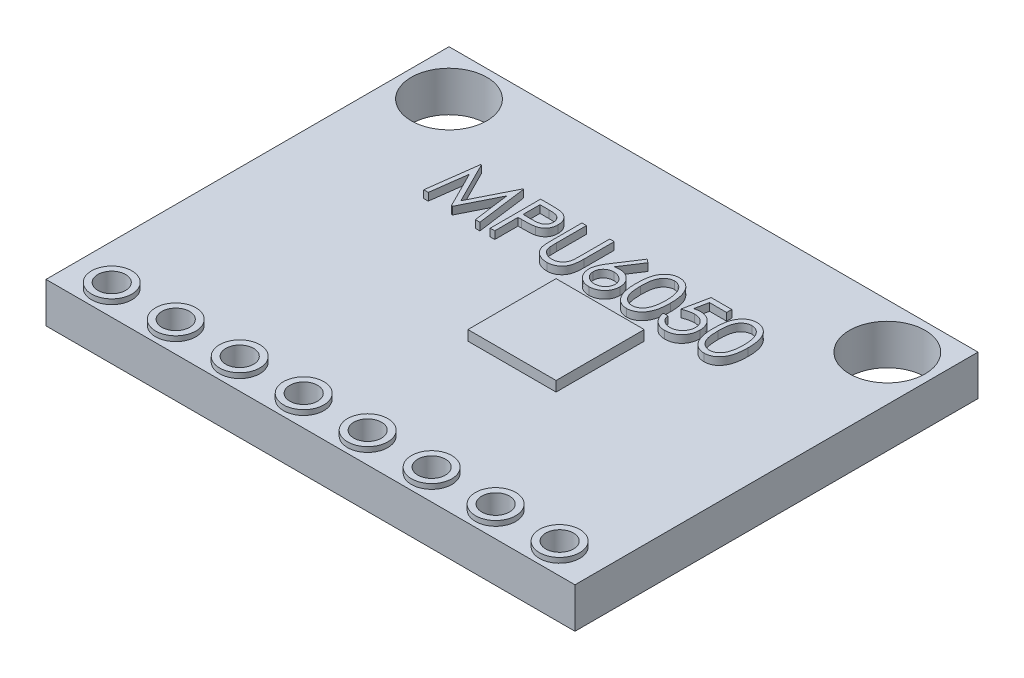
from build123d import *

# Parameters (mm, degrees)
SKETCH1_W           = 21
SKETCH1_H           = 16
SKETCH1_W_2         = 3.5
SKETCH1_H_2         = 3.5
SKETCH1_R           = 0.8
SKETCH1_R_2         = 1.5
BOSS_EXTRUDE1_DEPTH = 1.6
SKETCH1_3_W         = 3.5
SKETCH1_3_H         = 3.5
BOSS_EXTRUDE2_DEPTH = 2
SKETCH1_4_R         = 0.8
SKETCH1_4_R_2       = 0.55
BOSS_EXTRUDE3_DEPTH = 1.8
BOSS_EXTRUDE4_DEPTH = 0.3


with BuildPart() as part:
    # Sketch1 → Boss-Extrude1 (new body)
    with BuildSketch(Plane(origin=(0, 0, 0), x_dir=(1, 0, 0), z_dir=(0, 1, 0))):
        with Locations((10.5, 8)):
            Rectangle(SKETCH1_W, SKETCH1_H)
        with Locations((12.25, 8)):
            Rectangle(SKETCH1_W_2, SKETCH1_H_2, mode=Mode.SUBTRACT)
        with Locations((11.77, 1)):
            Circle(SKETCH1_R, mode=Mode.SUBTRACT)
        with Locations((14.31, 1)):
            Circle(SKETCH1_R, mode=Mode.SUBTRACT)
        with Locations((16.85, 1)):
            Circle(SKETCH1_R, mode=Mode.SUBTRACT)
        with Locations((19.39, 1)):
            Circle(SKETCH1_R, mode=Mode.SUBTRACT)
        with Locations((19.2, 14.2)):
            Circle(SKETCH1_R_2, mode=Mode.SUBTRACT)
        with Locations((9.23, 1)):
            Circle(SKETCH1_R, mode=Mode.SUBTRACT)
        with Locations((1.8, 14.2)):
            Circle(SKETCH1_R_2, mode=Mode.SUBTRACT)
        with Locations((1.61, 1)):
            Circle(SKETCH1_R, mode=Mode.SUBTRACT)
        with Locations((4.15, 1)):
            Circle(SKETCH1_R, mode=Mode.SUBTRACT)
        with Locations((6.69, 1)):
            Circle(SKETCH1_R, mode=Mode.SUBTRACT)
    extrude(amount=BOSS_EXTRUDE1_DEPTH)

    # Sketch1_3 → Boss-Extrude2 (add)
    with BuildSketch(Plane(origin=(0, 0, 0), x_dir=(1, 0, 0), z_dir=(0, 1, 0))):
        with Locations((12.25, 8)):
            Rectangle(SKETCH1_3_W, SKETCH1_3_H)
    extrude(amount=BOSS_EXTRUDE2_DEPTH)

    # Sketch1_4 → Boss-Extrude3 (add)
    # profile 1 of 8: a face of its own
    with BuildSketch(Plane(origin=(0, 0, 0), x_dir=(1, 0, 0), z_dir=(0, 1, 0))):
        with Locations((1.61, 1)):
            Circle(SKETCH1_4_R)
        with Locations((1.61, 1)):
            Circle(SKETCH1_4_R_2, mode=Mode.SUBTRACT)
    # profile 2 of 8: a face of its own
    with BuildSketch(Plane(origin=(0, 0, 0), x_dir=(1, 0, 0), z_dir=(0, 1, 0))):
        with Locations((4.15, 1)):
            Circle(SKETCH1_4_R)
        with Locations((4.15, 1)):
            Circle(SKETCH1_4_R_2, mode=Mode.SUBTRACT)
    # profile 3 of 8: a face of its own
    with BuildSketch(Plane(origin=(0, 0, 0), x_dir=(1, 0, 0), z_dir=(0, 1, 0))):
        with Locations((6.69, 1)):
            Circle(SKETCH1_4_R)
        with Locations((6.69, 1)):
            Circle(SKETCH1_4_R_2, mode=Mode.SUBTRACT)
    # profile 4 of 8: a face of its own
    with BuildSketch(Plane(origin=(0, 0, 0), x_dir=(1, 0, 0), z_dir=(0, 1, 0))):
        with Locations((9.23, 1)):
            Circle(SKETCH1_4_R)
        with Locations((9.23, 1)):
            Circle(SKETCH1_4_R_2, mode=Mode.SUBTRACT)
    # profile 5 of 8: a face of its own
    with BuildSketch(Plane(origin=(0, 0, 0), x_dir=(1, 0, 0), z_dir=(0, 1, 0))):
        with Locations((11.77, 1)):
            Circle(SKETCH1_4_R)
        with Locations((11.77, 1)):
            Circle(SKETCH1_4_R_2, mode=Mode.SUBTRACT)
    # profile 6 of 8: a face of its own
    with BuildSketch(Plane(origin=(0, 0, 0), x_dir=(1, 0, 0), z_dir=(0, 1, 0))):
        with Locations((14.31, 1)):
            Circle(SKETCH1_4_R)
        with Locations((14.31, 1)):
            Circle(SKETCH1_4_R_2, mode=Mode.SUBTRACT)
    # profile 7 of 8: a face of its own
    with BuildSketch(Plane(origin=(0, 0, 0), x_dir=(1, 0, 0), z_dir=(0, 1, 0))):
        with Locations((16.85, 1)):
            Circle(SKETCH1_4_R)
        with Locations((16.85, 1)):
            Circle(SKETCH1_4_R_2, mode=Mode.SUBTRACT)
    # profile 8 of 8: a face of its own
    with BuildSketch(Plane(origin=(0, 0, 0), x_dir=(1, 0, 0), z_dir=(0, 1, 0))):
        with Locations((19.39, 1)):
            Circle(SKETCH1_4_R)
        with Locations((19.39, 1)):
            Circle(SKETCH1_4_R_2, mode=Mode.SUBTRACT)
    extrude(amount=BOSS_EXTRUDE3_DEPTH)

    # Sketch3 → Boss-Extrude4 (add)
    # profile 1 of 7: a face of its own
    with BuildSketch(Plane(origin=(0, 1.6, 0), x_dir=(1, 0, 0), z_dir=(0, 1, 0))):
        Polygon((4.716844776, 10.278041451), (4.980867212, 12.278041451), (5.006508237, 12.278041451), (5.832229391, 10.63701581), (6.65594734, 12.278041451), (6.681989007, 12.278041451), (6.947614007, 10.278041451), (6.767325545, 10.278041451), (6.575819135, 11.717144015), (5.853864007, 10.278041451), (5.813399263, 10.278041451), (5.088639648, 11.720349143), (4.897533878, 10.278041451), align=None)
    # profile 2 of 7: a face of its own
    with BuildSketch(Plane(origin=(0, 1.6, 0), x_dir=(1, 0, 0), z_dir=(0, 1, 0))):
        with BuildLine():
            Line((7.357870417, 12.278041451), (7.750097981, 12.278041451))
            add(Edge.make_bspline(
                [(7.750097981, 12.278041451), (7.777075642, 12.278011796), (7.828766038, 12.277954975), (7.902888927, 12.276232264), (7.970208773, 12.273931297), (8.030580419, 12.270741643), (8.084189618, 12.266972163), (8.13079379, 12.261685284), (8.17075925, 12.256165115), (8.194705793, 12.250552882), (8.205626827, 12.247993374)],
                knots=[0, 0, 0, 0, 1.415646017, 2.712440637, 3.8905458, 4.950247383, 5.884950622, 6.709939814, 7.411656543, 8, 8, 8, 8], degree=3))
            add(Edge.make_bspline(
                [(8.205626827, 12.247993374), (8.219451704, 12.244209402), (8.246775691, 12.236730624), (8.286147715, 12.221751354), (8.323607056, 12.203990117), (8.359282232, 12.183747865), (8.392734851, 12.160156114), (8.424464017, 12.13417119), (8.45418972, 12.105193151), (8.481744801, 12.073547014), (8.5070504, 12.039764036), (8.52883879, 12.003339905), (8.54708292, 11.964887732), (8.562730503, 11.924434262), (8.573992477, 11.881639792), (8.58247642, 11.836801671), (8.58786135, 11.789924705), (8.5883771, 11.757890495), (8.588639648, 11.741583117)],
                knots=[0, 0, 0, 0, 0.999701418, 1.975846123, 2.934577507, 3.890451536, 4.834027766, 5.787354733, 6.749476667, 7.726910423, 8.712836071, 9.690891519, 10.682875813, 11.679750201, 12.712814741, 13.765529915, 14.8625177, 16, 16, 16, 16], degree=3))
            add(Edge.make_bspline(
                [(8.588639648, 11.741583117), (8.588398834, 11.725138673), (8.587927664, 11.692964008), (8.582272644, 11.645893844), (8.574655392, 11.600911906), (8.562942791, 11.558117935), (8.547602406, 11.517766066), (8.529606947, 11.479239648), (8.507902073, 11.443194121), (8.48296217, 11.409498625), (8.455218402, 11.378121532), (8.424788151, 11.349290221), (8.39179427, 11.323173456), (8.356341614, 11.299712689), (8.318084557, 11.279451957), (8.277603327, 11.261304926), (8.23454606, 11.24606432), (8.204750338, 11.238047142), (8.189601186, 11.233970938)],
                knots=[0, 0, 0, 0, 1.121902311, 2.195077645, 3.232258892, 4.234102512, 5.217864754, 6.176164875, 7.132989551, 8.084763148, 9.034132444, 9.988522005, 10.94243251, 11.903244335, 12.886203696, 13.894208494, 14.929344452, 16, 16, 16, 16], degree=3))
            add(Edge.make_bspline(
                [(8.189601186, 11.233970938), (8.177071281, 11.231306377), (8.149611265, 11.225466838), (8.104386853, 11.21894772), (8.051732346, 11.213383376), (7.991719615, 11.209211298), (7.924402527, 11.205639659), (7.849744665, 11.202800748), (7.767599478, 11.201240831), (7.710301625, 11.201160378), (7.680386443, 11.201118374)],
                knots=[0, 0, 0, 0, 0.601384939, 1.31797006, 2.144135048, 3.087295005, 4.142315834, 5.309527816, 6.595305764, 8, 8, 8, 8], degree=3))
            Line((7.680386443, 11.201118374), (7.537357596, 11.201118374))
            Line((7.537357596, 11.201118374), (7.537357596, 10.278041451))
            Line((7.537357596, 10.278041451), (7.357870417, 10.278041451))
            Line((7.357870417, 10.278041451), (7.357870417, 12.278041451))
        make_face()
        with BuildLine():
            Line((7.537357596, 12.072913246), (7.537357596, 11.406246579))
            Line((7.537357596, 11.406246579), (7.887517853, 11.401839528))
            add(Edge.make_bspline(
                [(7.887517853, 11.401839528), (7.904614953, 11.401830691), (7.937620553, 11.401813633), (7.985298395, 11.404090903), (8.029532274, 11.406719779), (8.070186317, 11.410568878), (8.107278851, 11.416009597), (8.140871724, 11.421502019), (8.170704457, 11.42944794), (8.205618287, 11.440146837), (8.244523057, 11.458394046), (8.28684737, 11.484879697), (8.322716277, 11.518640102), (8.353755304, 11.556598863), (8.378387234, 11.598826937), (8.396419229, 11.644009186), (8.407014176, 11.691682243), (8.408434859, 11.724304037), (8.409152468, 11.740781835)],
                knots=[0, 0, 0, 0, 1.160613943, 2.240541288, 3.23993089, 4.169200891, 5.011653406, 5.7853311, 6.478053781, 7.106038997, 8.262395093, 9.384106736, 10.481365981, 11.59014053, 12.70357646, 13.786202915, 14.881775077, 16, 16, 16, 16], degree=3))
            add(Edge.make_bspline(
                [(8.409152468, 11.740781835), (8.408430956, 11.756860986), (8.406996679, 11.788824347), (8.396336186, 11.835669353), (8.378422292, 11.88037547), (8.353589952, 11.922074376), (8.323452164, 11.95989655), (8.288423968, 11.992752051), (8.248587818, 12.019164452), (8.211531686, 12.036212042), (8.178616723, 12.046620771), (8.150027031, 12.053903537), (8.117746646, 12.059718169), (8.081765058, 12.064426456), (8.042361153, 12.068457005), (7.999196401, 12.071191849), (7.952434319, 12.072792682), (7.919971136, 12.072872085), (7.903142853, 12.072913246)],
                knots=[0, 0, 0, 0, 1.120700087, 2.227813068, 3.331159281, 4.466773991, 5.599788987, 6.693661531, 7.80175334, 8.91857717, 9.525282508, 10.207424825, 10.974604443, 11.810962634, 12.737642355, 13.736264703, 14.826523623, 16, 16, 16, 16], degree=3))
            Line((7.903142853, 12.072913246), (7.537357596, 12.072913246))
        make_face(mode=Mode.SUBTRACT)
    # profile 3 of 7: a face of its own
    with BuildSketch(Plane(origin=(0, 1.6, 0), x_dir=(1, 0, 0), z_dir=(0, 1, 0))):
        with BuildLine():
            Line((8.998896058, 12.278041451), (9.178383237, 12.278041451))
            Line((9.178383237, 12.278041451), (9.178383237, 11.079724143))
            add(Edge.make_bspline(
                [(9.178383237, 11.079724143), (9.178356527, 11.062763723), (9.178305838, 11.030578402), (9.178644418, 10.984767945), (9.179592628, 10.944040825), (9.180190434, 10.908240055), (9.181520338, 10.877529914), (9.182604937, 10.851744022), (9.18399954, 10.831004478), (9.185675608, 10.818901091), (9.186396058, 10.813698502)],
                knots=[0, 0, 0, 0, 1.528628734, 2.90083645, 4.128790002, 5.200304208, 6.127813768, 6.898992206, 7.526736466, 8, 8, 8, 8], degree=3))
            add(Edge.make_bspline(
                [(9.186396058, 10.813698502), (9.189354606, 10.794928923), (9.195104998, 10.758447363), (9.209760071, 10.706499774), (9.230227214, 10.659681798), (9.254480382, 10.616532488), (9.286441874, 10.578252854), (9.324729608, 10.542989053), (9.371116905, 10.512148021), (9.422694394, 10.483947557), (9.478285958, 10.461281796), (9.535092396, 10.444142731), (9.592259813, 10.433697645), (9.630531907, 10.432488194), (9.649537084, 10.431887605)],
                knots=[0, 0, 0, 0, 1.035780045, 2.013197591, 2.933192213, 3.817615948, 4.702609284, 5.640816605, 6.646850145, 7.73207398, 8.84249596, 9.914020372, 10.964143139, 12, 12, 12, 12], degree=3))
            add(Edge.make_bspline(
                [(9.649537084, 10.431887605), (9.665853507, 10.432501233), (9.698392113, 10.433724947), (9.746738645, 10.441302907), (9.793824422, 10.454960373), (9.839881953, 10.472583092), (9.883053944, 10.49586743), (9.923364482, 10.522765053), (9.959343873, 10.554314125), (9.992177015, 10.589228607), (10.020768407, 10.628622779), (10.045551916, 10.671638858), (10.065852448, 10.718924199), (10.075877319, 10.752155297), (10.081027468, 10.769227348)],
                knots=[0, 0, 0, 0, 0.994687771, 1.983630487, 2.973142513, 3.978332533, 4.983357753, 5.956394766, 6.925816176, 7.893390482, 8.871859704, 9.88551698, 10.913711441, 12, 12, 12, 12], degree=3))
            add(Edge.make_bspline(
                [(10.081027468, 10.769227348), (10.082741826, 10.776283676), (10.086562105, 10.792008019), (10.090131844, 10.818591614), (10.093849859, 10.849956965), (10.096429613, 10.886329429), (10.098944596, 10.927587128), (10.100449209, 10.973944989), (10.101144657, 11.025234681), (10.101351903, 11.061027345), (10.101460161, 11.079724143)],
                knots=[0, 0, 0, 0, 0.558680831, 1.244966039, 2.062412453, 2.990489873, 4.051219941, 5.244515665, 6.560634259, 8, 8, 8, 8], degree=3))
            Line((10.101460161, 11.079724143), (10.101460161, 12.278041451))
            Line((10.101460161, 12.278041451), (10.28094734, 12.278041451))
            Line((10.28094734, 12.278041451), (10.28094734, 11.070108758))
            add(Edge.make_bspline(
                [(10.28094734, 11.070108758), (10.280802128, 11.048338256), (10.280518739, 11.005851797), (10.278061267, 10.943593878), (10.274142981, 10.884535031), (10.268606931, 10.828667319), (10.2612715, 10.776190657), (10.253114232, 10.726645075), (10.242725927, 10.680386222), (10.230592555, 10.637053412), (10.216721956, 10.595804547), (10.198755586, 10.556656767), (10.178513014, 10.518419967), (10.154504641, 10.481672477), (10.127526708, 10.446251589), (10.096982891, 10.412372118), (10.06388337, 10.379492663), (10.027677907, 10.348456625), (9.988963322, 10.319994524), (9.947854774, 10.294967226), (9.904668049, 10.273810873), (9.859515405, 10.256396059), (9.812377575, 10.243302003), (9.763253369, 10.233544771), (9.712030973, 10.228000601), (9.677194027, 10.227176641), (9.659553109, 10.226759399)],
                knots=[0, 0, 0, 0, 1.316592851, 2.569410997, 3.76748051, 4.895814652, 5.963796859, 6.97159953, 7.931736103, 8.829262218, 9.692595152, 10.560224239, 11.431080259, 12.30701507, 13.211635791, 14.121146779, 15.063487852, 16.031507147, 17.00238618, 17.966455255, 18.938106653, 19.907068911, 20.888905087, 21.893141452, 22.933117798, 24, 24, 24, 24], degree=3))
            add(Edge.make_bspline(
                [(9.659553109, 10.226759399), (9.640313622, 10.227207837), (9.602565817, 10.228087669), (9.546944064, 10.233129241), (9.493621666, 10.242625466), (9.442035451, 10.254716862), (9.392887738, 10.271393284), (9.345520056, 10.290877926), (9.300743667, 10.314807789), (9.257832164, 10.341432585), (9.217932304, 10.371389522), (9.181305216, 10.404041049), (9.147890433, 10.438864122), (9.118251178, 10.47623576), (9.091896387, 10.515865307), (9.069193408, 10.557864872), (9.049700125, 10.602218196), (9.03963923, 10.633048596), (9.034553109, 10.648634399)],
                knots=[0, 0, 0, 0, 1.13879206, 2.234305948, 3.301075583, 4.341971843, 5.366689343, 6.369221514, 7.369726634, 8.367512178, 9.355451585, 10.318319045, 11.268648973, 12.207971039, 13.137398894, 14.081662264, 15.030215811, 16, 16, 16, 16], degree=3))
            add(Edge.make_bspline(
                [(9.034553109, 10.648634399), (9.031594733, 10.659281585), (9.02517795, 10.682375567), (9.018306351, 10.720596418), (9.012529733, 10.764604942), (9.007097985, 10.814404153), (9.003892866, 10.870032648), (9.001082901, 10.931466314), (8.998876262, 10.998779435), (8.998889275, 11.04566773), (8.998896058, 11.070108758)],
                knots=[0, 0, 0, 0, 0.625038921, 1.35572334, 2.194682327, 3.136881307, 4.189498639, 5.346923369, 6.617055217, 8, 8, 8, 8], degree=3))
            Line((8.998896058, 11.070108758), (8.998896058, 12.278041451))
        make_face()
    # profile 4 of 7: a face of its own
    with BuildSketch(Plane(origin=(0, 1.6, 0), x_dir=(1, 0, 0), z_dir=(0, 1, 0))):
        with BuildLine():
            Line((11.537357596, 12.329323502), (11.67557875, 12.220749784))
            Line((11.67557875, 12.220749784), (11.147133237, 11.412656835))
            add(Edge.make_bspline(
                [(11.147133237, 11.412656835), (11.182316253, 11.418264756), (11.250944702, 11.429203638), (11.32041093, 11.431008179), (11.354264648, 11.431887605)],
                knots=[0, 0, 0, 0, 1.025318673, 2, 2, 2, 2], degree=3))
            add(Edge.make_bspline(
                [(11.354264648, 11.431887605), (11.374591788, 11.431341255), (11.41460516, 11.430265782), (11.473351904, 11.421989296), (11.529802725, 11.408946375), (11.583723646, 11.389933657), (11.635308207, 11.365646598), (11.684852434, 11.336538672), (11.731425011, 11.301106854), (11.775625685, 11.26152688), (11.815755454, 11.217688603), (11.851284629, 11.171173553), (11.88112851, 11.122030193), (11.90534218, 11.070283412), (11.924144967, 11.016012978), (11.937852193, 10.959288327), (11.945954818, 10.900070343), (11.947055098, 10.8597971), (11.947614007, 10.839339528)],
                knots=[0, 0, 0, 0, 1.04369286, 2.054478336, 3.041073146, 4.015093852, 4.984733326, 5.965804835, 6.960378782, 7.985147595, 9.009457201, 10.008161701, 10.986880575, 11.956520048, 12.937015923, 13.931873656, 14.949455224, 16, 16, 16, 16], degree=3))
            add(Edge.make_bspline(
                [(11.947614007, 10.839339528), (11.946800804, 10.811351125), (11.945200613, 10.756276573), (11.929255587, 10.676061313), (11.904478647, 10.599642732), (11.869062917, 10.52824092), (11.825072983, 10.461953737), (11.771428645, 10.403219186), (11.710032366, 10.350836307), (11.640611338, 10.307032525), (11.565901073, 10.271259353), (11.487414217, 10.245564929), (11.405912991, 10.229745803), (11.350596072, 10.227762602), (11.322614007, 10.226759399)],
                knots=[0, 0, 0, 0, 1.031375318, 2.029502543, 3.004789286, 3.987476834, 4.960371455, 5.9300674, 6.912260825, 7.929083631, 8.949397511, 9.960523116, 10.96833055, 12, 12, 12, 12], degree=3))
            add(Edge.make_bspline(
                [(11.322614007, 10.226759399), (11.295701606, 10.22763266), (11.242392853, 10.229362436), (11.163974114, 10.244771543), (11.088623818, 10.26974703), (11.016869886, 10.30415519), (10.950400964, 10.347616837), (10.890934886, 10.399938139), (10.838768158, 10.460000691), (10.795354089, 10.527795175), (10.760920528, 10.600646579), (10.735097714, 10.676610669), (10.720014146, 10.755410658), (10.717906399, 10.808828452), (10.716844776, 10.835733758)],
                knots=[0, 0, 0, 0, 1.012016664, 2.004627821, 2.994792927, 3.992885782, 4.990978636, 5.973936114, 6.964471063, 7.975201453, 8.993600317, 9.990122807, 10.98767138, 12, 12, 12, 12], degree=3))
            add(Edge.make_bspline(
                [(10.716844776, 10.835733758), (10.717519887, 10.856330663), (10.718898336, 10.898385607), (10.72852313, 10.962079337), (10.743988727, 11.027251384), (10.761308868, 11.082539495), (10.779609217, 11.127831793), (10.794839239, 11.164348073), (10.813795809, 11.201925829), (10.834009169, 11.241853621), (10.857298809, 11.28310244), (10.882622037, 11.32636168), (10.91067898, 11.370943353), (10.930347645, 11.401197179), (10.940402468, 11.416663246)],
                knots=[0, 0, 0, 0, 1.173818275, 2.396712641, 3.66331629, 4.989737886, 5.693666774, 6.447286557, 7.243889047, 8.091586357, 8.998013824, 9.943181721, 10.948533338, 12, 12, 12, 12], degree=3))
            Line((10.940402468, 11.416663246), (11.537357596, 12.329323502))
        make_face()
        with BuildLine():
            add(Edge.make_bspline(
                [(11.316604391, 11.226759399), (11.301368823, 11.226314803), (11.271609332, 11.225446377), (11.227947952, 11.220403376), (11.186626094, 11.210906767), (11.147096303, 11.19881172), (11.110097616, 11.1821814), (11.075361136, 11.161980372), (11.042752535, 11.138196842), (11.012613362, 11.11116775), (10.985287841, 11.081574588), (10.961755766, 11.049877719), (10.941457252, 11.016841031), (10.924953355, 10.982188493), (10.912101883, 10.94593335), (10.90280574, 10.90824235), (10.897632168, 10.868862747), (10.896771464, 10.84215846), (10.896331955, 10.82852222)],
                knots=[0, 0, 0, 0, 1.129588631, 2.206414736, 3.251139165, 4.268635594, 5.265702196, 6.250456724, 7.242448911, 8.251968645, 9.246821453, 10.222880186, 11.173611482, 12.116736599, 13.062300278, 14.020270554, 14.989073742, 16, 16, 16, 16], degree=3))
            add(Edge.make_bspline(
                [(10.896331955, 10.82852222), (10.896689876, 10.815007946), (10.897391706, 10.788508466), (10.90376446, 10.749457506), (10.913498793, 10.711877558), (10.927979019, 10.675962359), (10.945251526, 10.641164463), (10.968054569, 10.6087443), (10.993321304, 10.576732831), (11.023523551, 10.547589133), (11.055936902, 10.520471062), (11.09056616, 10.49676806), (11.126657566, 10.476490247), (11.164698378, 10.460598191), (11.204148883, 10.447555742), (11.245337772, 10.438377754), (11.288293689, 10.433188882), (11.317391939, 10.432327057), (11.332229391, 10.431887605)],
                knots=[0, 0, 0, 0, 0.989467248, 1.94019797, 2.891935182, 3.827694429, 4.772920941, 5.730924762, 6.725747692, 7.756678648, 8.79901574, 9.819492441, 10.826891316, 11.826466727, 12.835195252, 13.867842842, 14.912794438, 16, 16, 16, 16], degree=3))
            add(Edge.make_bspline(
                [(11.332229391, 10.431887605), (11.347066819, 10.432327091), (11.376165022, 10.433188984), (11.419121285, 10.438377366), (11.460308895, 10.447557165), (11.499764043, 10.460593033), (11.537787718, 10.476509382), (11.573847559, 10.496641907), (11.608149327, 10.520616832), (11.640583955, 10.547542791), (11.670660491, 10.576898706), (11.696533222, 10.608458547), (11.718637927, 10.641426488), (11.736600319, 10.675825282), (11.750921057, 10.711899275), (11.760704753, 10.749451688), (11.767064346, 10.788509989), (11.767767984, 10.81500846), (11.768126827, 10.82852222)],
                knots=[0, 0, 0, 0, 1.087397944, 2.132534446, 3.165364764, 4.174271784, 5.174024072, 6.181601208, 7.194203697, 8.236725232, 9.267838612, 10.269026844, 11.221737037, 12.171628256, 13.107553087, 14.05945871, 15.010357665, 16, 16, 16, 16], degree=3))
            add(Edge.make_bspline(
                [(11.768126827, 10.82852222), (11.767812374, 10.842176249), (11.767195205, 10.868974668), (11.760214663, 10.908224735), (11.750533306, 10.946124853), (11.735914432, 10.982436824), (11.71692212, 11.017017354), (11.693788745, 11.050041126), (11.667027276, 11.081761324), (11.636114396, 11.111225786), (11.602462834, 11.138166973), (11.5666825, 11.161949577), (11.529249372, 11.182020992), (11.490201405, 11.198767908), (11.449091186, 11.210853322), (11.406582421, 11.220369461), (11.362131425, 11.225433471), (11.331973363, 11.226311794), (11.316604391, 11.226759399)],
                knots=[0, 0, 0, 0, 0.978206639, 1.919901502, 2.851605144, 3.780102724, 4.718870031, 5.675451981, 6.667674623, 7.690630536, 8.733308323, 9.756129687, 10.767539656, 11.776269907, 12.797430371, 13.836405707, 14.897401972, 16, 16, 16, 16], degree=3))
        make_face(mode=Mode.SUBTRACT)
    # profile 5 of 7: a face of its own
    with BuildSketch(Plane(origin=(0, 1.6, 0), x_dir=(1, 0, 0), z_dir=(0, 1, 0))):
        with BuildLine():
            add(Edge.make_bspline(
                [(12.152742212, 11.277240169), (12.152929651, 11.309295819), (12.153293754, 11.371564381), (12.15734428, 11.462298462), (12.164073047, 11.547418628), (12.173294403, 11.626928951), (12.184516106, 11.700849959), (12.199496384, 11.768984106), (12.216532271, 11.831646739), (12.236276526, 11.889042195), (12.258555262, 11.941943739), (12.282803411, 11.991329569), (12.309983294, 12.037124959), (12.33854153, 12.080060839), (12.369634142, 12.119434379), (12.402376308, 12.155801614), (12.438045952, 12.188322043), (12.475430528, 12.217948502), (12.514868508, 12.243919628), (12.555235745, 12.266795479), (12.596810092, 12.28633826), (12.639705053, 12.301704224), (12.683535086, 12.314396136), (12.72845341, 12.323075535), (12.77453419, 12.328536625), (12.805637867, 12.329058721), (12.821412084, 12.329323502)],
                knots=[0, 0, 0, 0, 1.646270934, 3.197905019, 4.663502075, 6.030701355, 7.308322542, 8.50163776, 9.611534131, 10.641858119, 11.616356847, 12.558055219, 13.465016945, 14.349605745, 15.204443733, 16.039544428, 16.859896111, 17.680448484, 18.487036065, 19.28249412, 20.06191084, 20.843045899, 21.620316918, 22.403196591, 23.190181807, 24, 24, 24, 24], degree=3))
            add(Edge.make_bspline(
                [(12.821412084, 12.329323502), (12.837318071, 12.32904475), (12.868950076, 12.328490401), (12.915716005, 12.323162434), (12.961401538, 12.314321792), (13.005811902, 12.301795521), (13.049311895, 12.286255135), (13.091561271, 12.266776782), (13.13282246, 12.244103143), (13.172439767, 12.217460928), (13.210848119, 12.18775677), (13.247104098, 12.154178102), (13.281211004, 12.117063977), (13.313596893, 12.076811483), (13.343342948, 12.032648578), (13.371670624, 11.985343372), (13.397026073, 11.934068592), (13.421445887, 11.879679753), (13.442524165, 11.820671948), (13.461533448, 11.757377799), (13.476892859, 11.689049693), (13.489686729, 11.616046124), (13.499598098, 11.538098991), (13.506816751, 11.455375382), (13.510629942, 11.367820873), (13.511348057, 11.307959245), (13.511716571, 11.277240169)],
                knots=[0, 0, 0, 0, 0.810914788, 1.612654377, 2.396697861, 3.181598691, 3.963628158, 4.749916497, 5.551656086, 6.361998678, 7.18212741, 8.025565596, 8.878627764, 9.750805457, 10.657531673, 11.591944965, 12.560506719, 13.57287815, 14.630710178, 15.753379473, 16.941251878, 18.199788006, 19.531962791, 20.947069417, 22.433333509, 24, 24, 24, 24], degree=3))
            add(Edge.make_bspline(
                [(13.511716571, 11.277240169), (13.511344237, 11.246655078), (13.510618759, 11.187061277), (13.506859498, 11.09990072), (13.499454566, 11.017616124), (13.490191716, 10.940010145), (13.477362594, 10.867405792), (13.461588213, 10.799551821), (13.444073743, 10.736155209), (13.422453861, 10.677735316), (13.398790598, 10.623477189), (13.373044771, 10.572810247), (13.345462013, 10.525286651), (13.315411302, 10.481286796), (13.28338078, 10.440498992), (13.248684901, 10.403643208), (13.212301709, 10.369831395), (13.173780329, 10.339744751), (13.133545157, 10.313410577), (13.092425684, 10.289859805), (13.049692322, 10.270869694), (13.006313492, 10.254563956), (12.961668711, 10.242106555), (12.915813631, 10.233492923), (12.868981496, 10.227451867), (12.837323459, 10.226991021), (12.821412084, 10.226759399)],
                knots=[0, 0, 0, 0, 1.561518951, 3.042555995, 4.452378317, 5.7783523, 7.031515105, 8.214008947, 9.334062868, 10.386615937, 11.391082383, 12.354592575, 13.286541444, 14.194233754, 15.072674879, 15.931287219, 16.775624067, 17.606195743, 18.42308326, 19.229000347, 20.022332153, 20.807536673, 21.593273796, 22.3848459, 23.188221202, 24, 24, 24, 24], degree=3))
            add(Edge.make_bspline(
                [(12.821412084, 10.226759399), (12.805638304, 10.227025888), (12.77453549, 10.227551352), (12.72844839, 10.23298777), (12.683715565, 10.241728058), (12.640116277, 10.253966117), (12.59742684, 10.268946024), (12.556228962, 10.288462414), (12.516064571, 10.310939025), (12.477040825, 10.336536409), (12.439891018, 10.365863085), (12.404406101, 10.398299821), (12.371477519, 10.434656056), (12.340829464, 10.474357727), (12.311701414, 10.517039579), (12.284907486, 10.563284364), (12.260124141, 10.612908713), (12.237470718, 10.666233233), (12.217385767, 10.724036049), (12.19964422, 10.786978437), (12.18563613, 10.855615943), (12.173645869, 10.929397296), (12.163974793, 11.008639542), (12.157372322, 11.093385701), (12.15329157, 11.183582963), (12.152928673, 11.245451405), (12.152742212, 11.277240169)],
                knots=[0, 0, 0, 0, 0.810891512, 1.598919785, 2.382837074, 3.152667961, 3.926044502, 4.706494248, 5.493654104, 6.291793342, 7.103789334, 7.925228297, 8.761435821, 9.622817696, 10.50288917, 11.416980706, 12.369136599, 13.353924996, 14.394355917, 15.514179734, 16.714354668, 17.994756427, 19.357759367, 20.818452758, 22.365282078, 24, 24, 24, 24], degree=3))
        make_face()
        with BuildLine():
            add(Edge.make_bspline(
                [(12.332229391, 11.278041451), (12.332297647, 11.251327909), (12.332430117, 11.199482169), (12.335890803, 11.124143162), (12.340605222, 11.053874403), (12.346685963, 10.988586668), (12.355716219, 10.928500946), (12.365834384, 10.873203985), (12.378147578, 10.822988421), (12.392716159, 10.777509672), (12.409309929, 10.735995918), (12.427427565, 10.697366652), (12.446890836, 10.661165546), (12.468673207, 10.62771777), (12.492396101, 10.596914247), (12.517523677, 10.568209772), (12.544993725, 10.542611497), (12.582995864, 10.511910437), (12.633165278, 10.480185217), (12.696376967, 10.45255888), (12.761330367, 10.435197477), (12.805416796, 10.432989616), (12.827421699, 10.431887605)],
                knots=[0, 0, 0, 0, 1.459021318, 2.831673884, 4.118529203, 5.306027144, 6.411944654, 7.436330062, 8.375795394, 9.233974572, 10.042671642, 10.816086306, 11.563610507, 12.285937304, 12.993564865, 13.685989202, 14.367179055, 15.041617293, 16.353048772, 17.594441528, 18.799311195, 20, 20, 20, 20], degree=3))
            add(Edge.make_bspline(
                [(12.827421699, 10.431887605), (12.84956894, 10.432800622), (12.893817696, 10.434624772), (12.958465579, 10.452224051), (13.021225733, 10.478778073), (13.070409699, 10.510176648), (13.107828295, 10.54007855), (13.134638004, 10.565572635), (13.159244889, 10.594118845), (13.182583217, 10.624918443), (13.203988404, 10.658559862), (13.223453054, 10.694881334), (13.241214967, 10.733983721), (13.251334421, 10.761280715), (13.256508237, 10.775236964)],
                knots=[0, 0, 0, 0, 1.353760809, 2.704726607, 4.075137775, 5.516104923, 6.260822281, 7.007110065, 7.778089737, 8.566572457, 9.372053459, 10.217411131, 11.088608312, 12, 12, 12, 12], degree=3))
            add(Edge.make_bspline(
                [(13.256508237, 10.775236964), (13.262537819, 10.793082529), (13.274780456, 10.82931668), (13.290558612, 10.885524481), (13.302984555, 10.944497489), (13.314163621, 11.00588327), (13.321793938, 11.070134528), (13.327935546, 11.137052461), (13.331553081, 11.206687526), (13.332001511, 11.253998949), (13.332229391, 11.278041451)],
                knots=[0, 0, 0, 0, 0.884706709, 1.796334032, 2.740027952, 3.714592787, 4.726048262, 5.777819803, 6.87074269, 8, 8, 8, 8], degree=3))
            add(Edge.make_bspline(
                [(13.332229391, 11.278041451), (13.331914997, 11.302080064), (13.331299976, 11.349104729), (13.328949126, 11.417972261), (13.322878512, 11.48338241), (13.316136158, 11.545616966), (13.306194889, 11.604331425), (13.295476142, 11.660017313), (13.281075449, 11.711984756), (13.265692721, 11.761047374), (13.248086781, 11.806647748), (13.228706361, 11.848998483), (13.208008213, 11.88830404), (13.185526933, 11.924456578), (13.1615294, 11.957618031), (13.135382229, 11.987123514), (13.108122587, 12.013887496), (13.069941338, 12.044437535), (13.01995603, 12.075587075), (12.957758517, 12.104253224), (12.893032434, 12.120715105), (12.849276175, 12.12303607), (12.827421699, 12.124195297)],
                knots=[0, 0, 0, 0, 1.31362396, 2.569729283, 3.763502607, 4.902122613, 5.988968491, 7.01645872, 7.998833611, 8.933434873, 9.825090667, 10.667526885, 11.477055099, 12.250526234, 12.991942729, 13.710640831, 14.402115721, 15.076753259, 16.378508321, 17.609869233, 18.806226677, 20, 20, 20, 20], degree=3))
            add(Edge.make_bspline(
                [(12.827421699, 12.124195297), (12.805301361, 12.12303447), (12.761020386, 12.120710702), (12.695621555, 12.104314557), (12.632933354, 12.07573572), (12.583080225, 12.044334364), (12.544872347, 12.014426757), (12.517967951, 11.988491641), (12.492741567, 11.960122352), (12.469502881, 11.929035544), (12.447737577, 11.895626763), (12.427748427, 11.859633183), (12.409738524, 11.820872403), (12.393118789, 11.779377297), (12.378505767, 11.733902472), (12.366452074, 11.683748761), (12.355316615, 11.62862768), (12.347433604, 11.568216533), (12.340425744, 11.502912445), (12.335922116, 11.432468263), (12.332418541, 11.357002903), (12.332293704, 11.304889098), (12.332229391, 11.278041451)],
                knots=[0, 0, 0, 0, 1.207732386, 2.417664972, 3.655092373, 4.956220595, 5.625982001, 6.301752483, 6.994047911, 7.697131622, 8.419323945, 9.170223765, 9.943494443, 10.752040957, 11.610060368, 12.549350801, 13.567764191, 14.679664412, 15.874934091, 17.154273443, 18.533957287, 20, 20, 20, 20], degree=3))
        make_face(mode=Mode.SUBTRACT)
    # profile 6 of 7: a face of its own
    with BuildSketch(Plane(origin=(0, 1.6, 0), x_dir=(1, 0, 0), z_dir=(0, 1, 0))):
        with BuildLine():
            Line((14.947614007, 12.278041451), (14.947614007, 12.072913246))
            Line((14.947614007, 12.072913246), (14.267325545, 12.072913246))
            Line((14.267325545, 12.072913246), (14.159553109, 11.546871579))
            add(Edge.make_bspline(
                [(14.159553109, 11.546871579), (14.180727895, 11.552717448), (14.221750692, 11.564042896), (14.282299184, 11.576617622), (14.339780443, 11.584197876), (14.377080655, 11.585232911), (14.395130032, 11.585733758)],
                knots=[0, 0, 0, 0, 1.100273476, 2.13160584, 3.095893838, 4, 4, 4, 4], degree=3))
            add(Edge.make_bspline(
                [(14.395130032, 11.585733758), (14.417463598, 11.585250367), (14.461376968, 11.584299897), (14.525627795, 11.575173126), (14.586960876, 11.560807461), (14.645247945, 11.540738591), (14.700596831, 11.515075887), (14.752498295, 11.483018778), (14.801731388, 11.44557116), (14.84741287, 11.402516867), (14.888855332, 11.355133086), (14.925293041, 11.304185732), (14.956243092, 11.250169925), (14.981134952, 11.192569577), (15.001011714, 11.132021489), (15.014241426, 11.067888585), (15.023050974, 11.000775373), (15.024035195, 10.954887048), (15.024537084, 10.931486964)],
                knots=[0, 0, 0, 0, 1.052922333, 2.070308379, 3.05430497, 4.020497103, 4.973039431, 5.925935799, 6.892292201, 7.88610001, 8.88166317, 9.857072816, 10.836096531, 11.812156883, 12.81219415, 13.836441305, 14.89672472, 16, 16, 16, 16], degree=3))
            add(Edge.make_bspline(
                [(15.024537084, 10.931486964), (15.024157041, 10.915188552), (15.023402091, 10.882811988), (15.019562898, 10.834729587), (15.01217106, 10.787665111), (15.002246646, 10.741612316), (14.989365264, 10.696658389), (14.973771519, 10.652674659), (14.954688075, 10.609934883), (14.933755861, 10.568034658), (14.910186445, 10.527921225), (14.884027297, 10.490407518), (14.856389874, 10.454930786), (14.826651939, 10.42187151), (14.794537085, 10.391446928), (14.760434247, 10.363476482), (14.72461555, 10.33748715), (14.68652684, 10.314533896), (14.64701685, 10.293412207), (14.605515012, 10.276084471), (14.56296604, 10.260592741), (14.51875754, 10.248244439), (14.472989647, 10.238568694), (14.425586918, 10.231996922), (14.376797964, 10.227210386), (14.343726528, 10.226910754), (14.327021058, 10.226759399)],
                knots=[0, 0, 0, 0, 1.056347294, 2.098418968, 3.122841568, 4.141288669, 5.149314143, 6.15115421, 7.162517403, 8.180376062, 9.185164535, 10.17417709, 11.141909838, 12.097768115, 13.052685741, 14.0056014, 14.954263652, 15.917497458, 16.885230207, 17.854509472, 18.828990115, 19.81800267, 20.826176721, 21.857883937, 22.917946725, 24, 24, 24, 24], degree=3))
            add(Edge.make_bspline(
                [(14.327021058, 10.226759399), (14.307092955, 10.227154164), (14.267886766, 10.227930817), (14.210446442, 10.236055665), (14.155180953, 10.247692189), (14.102535181, 10.265198629), (14.052037316, 10.287134226), (14.004367191, 10.314857752), (13.958306748, 10.346274383), (13.915728441, 10.383348871), (13.876210662, 10.423872117), (13.840835514, 10.467847912), (13.809330613, 10.514550451), (13.782200472, 10.564206539), (13.759058745, 10.616685699), (13.740878752, 10.672184557), (13.726205406, 10.730413131), (13.719997738, 10.770500851), (13.716844776, 10.790861964)],
                knots=[0, 0, 0, 0, 1.0467383, 2.05933395, 3.04377827, 4.011590433, 4.970194871, 5.932262533, 6.905835911, 7.896367577, 8.894135286, 9.877477877, 10.858688626, 11.851381753, 12.8477658, 13.868841284, 14.917554742, 16, 16, 16, 16], degree=3))
            Line((13.716844776, 10.790861964), (13.896331955, 10.790861964))
            add(Edge.make_bspline(
                [(13.896331955, 10.790861964), (13.900748274, 10.771789705), (13.909236683, 10.735131765), (13.92786854, 10.683628141), (13.95064904, 10.637731442), (13.977737239, 10.596834537), (14.010051542, 10.561172253), (14.046925502, 10.529391075), (14.088267058, 10.500719573), (14.134206046, 10.476820848), (14.182670663, 10.456438704), (14.233394783, 10.442866307), (14.284997266, 10.433322939), (14.319899192, 10.432367647), (14.337437725, 10.431887605)],
                knots=[0, 0, 0, 0, 1.136247022, 2.183929868, 3.172523383, 4.106158343, 5.02341133, 5.958108904, 6.928429099, 7.938127109, 8.96079061, 9.975095812, 10.982467395, 12, 12, 12, 12], degree=3))
            add(Edge.make_bspline(
                [(14.337437725, 10.431887605), (14.354556836, 10.43235662), (14.388264506, 10.433280117), (14.437871012, 10.440388124), (14.485764083, 10.451335307), (14.531471144, 10.467718082), (14.575792024, 10.487629349), (14.617605607, 10.513180821), (14.658121537, 10.542586546), (14.69608047, 10.576276049), (14.73084587, 10.613401589), (14.761563653, 10.653102956), (14.787150461, 10.69545544), (14.808712809, 10.739725813), (14.825086123, 10.786399274), (14.836766683, 10.835257089), (14.843625574, 10.886419934), (14.844569105, 10.921316683), (14.845049904, 10.939099143)],
                knots=[0, 0, 0, 0, 1.027316725, 2.022795036, 3.002884548, 3.971462791, 4.93288096, 5.914575861, 6.907176829, 7.935150275, 8.956128384, 9.956726525, 10.942570165, 11.921478529, 12.907843606, 13.90538589, 14.932640048, 16, 16, 16, 16], degree=3))
            add(Edge.make_bspline(
                [(14.845049904, 10.939099143), (14.84467363, 10.95514243), (14.843937127, 10.986544881), (14.837919659, 11.032487284), (14.827452817, 11.075957594), (14.812924886, 11.117165728), (14.794479453, 11.156150552), (14.771938703, 11.192952301), (14.744879618, 11.22708592), (14.713969968, 11.258567379), (14.68010823, 11.287621593), (14.642711806, 11.312389642), (14.602563276, 11.333226167), (14.560146362, 11.35120788), (14.514452134, 11.364122592), (14.466385487, 11.373818526), (14.415427369, 11.379427305), (14.380586975, 11.380205527), (14.362678109, 11.380605553)],
                knots=[0, 0, 0, 0, 1.045622112, 2.046656509, 3.013763289, 3.955457236, 4.890082067, 5.820317437, 6.762574623, 7.722996705, 8.69280354, 9.665887285, 10.63943826, 11.638615906, 12.663482002, 13.728887084, 14.832589034, 16, 16, 16, 16], degree=3))
            add(Edge.make_bspline(
                [(14.362678109, 11.380605553), (14.347175864, 11.380273787), (14.315167661, 11.379588773), (14.266068903, 11.374545061), (14.214473633, 11.366408321), (14.160579635, 11.35521618), (14.104225059, 11.34056985), (14.04552883, 11.323018707), (13.984367535, 11.302034708), (13.943157407, 11.286187729), (13.921972981, 11.278041451)],
                knots=[0, 0, 0, 0, 0.817624296, 1.688186739, 2.600797293, 3.572016777, 4.590301741, 5.671205678, 6.80286297, 8, 8, 8, 8], degree=3))
            Line((13.921972981, 11.278041451), (14.127101186, 12.278041451))
            Line((14.127101186, 12.278041451), (14.947614007, 12.278041451))
        make_face()
    # profile 7 of 7: a face of its own
    with BuildSketch(Plane(origin=(0, 1.6, 0), x_dir=(1, 0, 0), z_dir=(0, 1, 0))):
        with BuildLine():
            add(Edge.make_bspline(
                [(15.229665289, 11.277240169), (15.229852728, 11.309295819), (15.230216831, 11.371564381), (15.234267357, 11.462298462), (15.240996124, 11.547418628), (15.25021748, 11.626928951), (15.261439183, 11.700849959), (15.276419461, 11.768984106), (15.293455348, 11.831646739), (15.313199603, 11.889042195), (15.335478339, 11.941943739), (15.359726488, 11.991329569), (15.386906371, 12.037124959), (15.415464607, 12.080060839), (15.446557219, 12.119434379), (15.479299385, 12.155801614), (15.514969029, 12.188322043), (15.552353605, 12.217948502), (15.591791585, 12.243919628), (15.632158822, 12.266795479), (15.673733169, 12.28633826), (15.71662813, 12.301704224), (15.760458163, 12.314396136), (15.805376487, 12.323075535), (15.851457266, 12.328536625), (15.882560943, 12.329058721), (15.898335161, 12.329323502)],
                knots=[0, 0, 0, 0, 1.646270934, 3.197905019, 4.663502075, 6.030701355, 7.308322542, 8.50163776, 9.611534131, 10.641858119, 11.616356847, 12.558055219, 13.465016945, 14.349605745, 15.204443733, 16.039544428, 16.859896111, 17.680448484, 18.487036065, 19.28249412, 20.06191084, 20.843045899, 21.620316918, 22.403196591, 23.190181807, 24, 24, 24, 24], degree=3))
            add(Edge.make_bspline(
                [(15.898335161, 12.329323502), (15.914241148, 12.32904475), (15.945873153, 12.328490401), (15.992639082, 12.323162434), (16.038324614, 12.314321792), (16.082734979, 12.301795521), (16.126234972, 12.286255135), (16.168484347, 12.266776782), (16.209745537, 12.244103143), (16.249362844, 12.217460928), (16.287771196, 12.18775677), (16.324027175, 12.154178102), (16.358134081, 12.117063977), (16.39051997, 12.076811483), (16.420266025, 12.032648578), (16.448593701, 11.985343372), (16.47394915, 11.934068592), (16.498368964, 11.879679753), (16.519447242, 11.820671948), (16.538456525, 11.757377799), (16.553815936, 11.689049693), (16.566609806, 11.616046124), (16.576521175, 11.538098991), (16.583739828, 11.455375382), (16.587553019, 11.367820873), (16.588271134, 11.307959245), (16.588639648, 11.277240169)],
                knots=[0, 0, 0, 0, 0.810914788, 1.612654377, 2.396697861, 3.181598691, 3.963628158, 4.749916497, 5.551656086, 6.361998678, 7.18212741, 8.025565596, 8.878627764, 9.750805457, 10.657531673, 11.591944965, 12.560506719, 13.57287815, 14.630710178, 15.753379473, 16.941251878, 18.199788006, 19.531962791, 20.947069417, 22.433333509, 24, 24, 24, 24], degree=3))
            add(Edge.make_bspline(
                [(16.588639648, 11.277240169), (16.588267314, 11.246655078), (16.587541836, 11.187061277), (16.583782575, 11.09990072), (16.576377643, 11.017616124), (16.567114792, 10.940010145), (16.554285671, 10.867405792), (16.53851129, 10.799551821), (16.52099682, 10.736155209), (16.499376937, 10.677735316), (16.475713674, 10.623477189), (16.449967848, 10.572810247), (16.42238509, 10.525286651), (16.392334379, 10.481286796), (16.360303857, 10.440498992), (16.325607978, 10.403643208), (16.289224786, 10.369831395), (16.250703406, 10.339744751), (16.210468234, 10.313410577), (16.169348761, 10.289859805), (16.126615399, 10.270869694), (16.083236569, 10.254563956), (16.038591788, 10.242106555), (15.992736708, 10.233492923), (15.945904573, 10.227451867), (15.914246536, 10.226991021), (15.898335161, 10.226759399)],
                knots=[0, 0, 0, 0, 1.561518951, 3.042555995, 4.452378317, 5.7783523, 7.031515105, 8.214008947, 9.334062868, 10.386615937, 11.391082383, 12.354592575, 13.286541444, 14.194233754, 15.072674879, 15.931287219, 16.775624067, 17.606195743, 18.42308326, 19.229000347, 20.022332153, 20.807536673, 21.593273796, 22.3848459, 23.188221202, 24, 24, 24, 24], degree=3))
            add(Edge.make_bspline(
                [(15.898335161, 10.226759399), (15.882561381, 10.227025888), (15.851458567, 10.227551352), (15.805371467, 10.23298777), (15.760638642, 10.241728058), (15.717039354, 10.253966117), (15.674349917, 10.268946024), (15.633152039, 10.288462414), (15.592987648, 10.310939025), (15.553963902, 10.336536409), (15.516814095, 10.365863085), (15.481329178, 10.398299821), (15.448400596, 10.434656056), (15.417752541, 10.474357727), (15.388624491, 10.517039579), (15.361830563, 10.563284364), (15.337047218, 10.612908713), (15.314393795, 10.666233233), (15.294308844, 10.724036049), (15.276567296, 10.786978437), (15.262559207, 10.855615943), (15.250568946, 10.929397296), (15.24089787, 11.008639542), (15.234295399, 11.093385701), (15.230214647, 11.183582963), (15.22985175, 11.245451405), (15.229665289, 11.277240169)],
                knots=[0, 0, 0, 0, 0.810891512, 1.598919785, 2.382837074, 3.152667961, 3.926044502, 4.706494248, 5.493654104, 6.291793342, 7.103789334, 7.925228297, 8.761435821, 9.622817696, 10.50288917, 11.416980706, 12.369136599, 13.353924996, 14.394355917, 15.514179734, 16.714354668, 17.994756427, 19.357759367, 20.818452758, 22.365282078, 24, 24, 24, 24], degree=3))
        make_face()
        with BuildLine():
            add(Edge.make_bspline(
                [(15.409152468, 11.278041451), (15.409220724, 11.251327909), (15.409353194, 11.199482169), (15.41281388, 11.124143162), (15.417528298, 11.053874403), (15.42360904, 10.988586668), (15.432639296, 10.928500946), (15.44275746, 10.873203985), (15.455070655, 10.822988421), (15.469639236, 10.777509672), (15.486233006, 10.735995918), (15.504350642, 10.697366652), (15.523813912, 10.661165546), (15.545596284, 10.62771777), (15.569319177, 10.596914247), (15.594446754, 10.568209772), (15.621916802, 10.542611497), (15.659918941, 10.511910437), (15.710088355, 10.480185217), (15.773300044, 10.45255888), (15.838253444, 10.435197477), (15.882339873, 10.432989616), (15.904344776, 10.431887605)],
                knots=[0, 0, 0, 0, 1.459021318, 2.831673884, 4.118529203, 5.306027144, 6.411944654, 7.436330062, 8.375795394, 9.233974572, 10.042671642, 10.816086306, 11.563610507, 12.285937304, 12.993564865, 13.685989202, 14.367179055, 15.041617293, 16.353048772, 17.594441528, 18.799311195, 20, 20, 20, 20], degree=3))
            add(Edge.make_bspline(
                [(15.904344776, 10.431887605), (15.926492017, 10.432800622), (15.970740773, 10.434624772), (16.035388656, 10.452224051), (16.09814881, 10.478778073), (16.147332776, 10.510176648), (16.184751372, 10.54007855), (16.211561081, 10.565572635), (16.236167966, 10.594118845), (16.259506294, 10.624918443), (16.28091148, 10.658559862), (16.300376131, 10.694881334), (16.318138043, 10.733983721), (16.328257498, 10.761280715), (16.333431314, 10.775236964)],
                knots=[0, 0, 0, 0, 1.353760809, 2.704726607, 4.075137775, 5.516104923, 6.260822281, 7.007110065, 7.778089737, 8.566572457, 9.372053459, 10.217411131, 11.088608312, 12, 12, 12, 12], degree=3))
            add(Edge.make_bspline(
                [(16.333431314, 10.775236964), (16.339460896, 10.793082529), (16.351703532, 10.82931668), (16.367481689, 10.885524481), (16.379907632, 10.944497489), (16.391086698, 11.00588327), (16.398717015, 11.070134528), (16.404858623, 11.137052461), (16.408476158, 11.206687526), (16.408924588, 11.253998949), (16.409152468, 11.278041451)],
                knots=[0, 0, 0, 0, 0.884706709, 1.796334032, 2.740027952, 3.714592787, 4.726048262, 5.777819803, 6.87074269, 8, 8, 8, 8], degree=3))
            add(Edge.make_bspline(
                [(16.409152468, 11.278041451), (16.408838074, 11.302080064), (16.408223053, 11.349104729), (16.405872203, 11.417972261), (16.399801589, 11.48338241), (16.393059235, 11.545616966), (16.383117966, 11.604331425), (16.372399219, 11.660017313), (16.357998526, 11.711984756), (16.342615798, 11.761047374), (16.325009857, 11.806647748), (16.305629438, 11.848998483), (16.28493129, 11.88830404), (16.26245001, 11.924456578), (16.238452477, 11.957618031), (16.212305306, 11.987123514), (16.185045664, 12.013887496), (16.146864415, 12.044437535), (16.096879107, 12.075587075), (16.034681594, 12.104253224), (15.969955511, 12.120715105), (15.926199252, 12.12303607), (15.904344776, 12.124195297)],
                knots=[0, 0, 0, 0, 1.31362396, 2.569729283, 3.763502607, 4.902122613, 5.988968491, 7.01645872, 7.998833611, 8.933434873, 9.825090667, 10.667526885, 11.477055099, 12.250526234, 12.991942729, 13.710640831, 14.402115721, 15.076753259, 16.378508321, 17.609869233, 18.806226677, 20, 20, 20, 20], degree=3))
            add(Edge.make_bspline(
                [(15.904344776, 12.124195297), (15.882224438, 12.12303447), (15.837943463, 12.120710702), (15.772544632, 12.104314557), (15.709856431, 12.07573572), (15.660003302, 12.044334364), (15.621795424, 12.014426757), (15.594891028, 11.988491641), (15.569664644, 11.960122352), (15.546425958, 11.929035544), (15.524660654, 11.895626763), (15.504671503, 11.859633183), (15.486661601, 11.820872403), (15.470041866, 11.779377297), (15.455428844, 11.733902472), (15.443375151, 11.683748761), (15.432239692, 11.62862768), (15.424356681, 11.568216533), (15.417348821, 11.502912445), (15.412845193, 11.432468263), (15.409341618, 11.357002903), (15.409216781, 11.304889098), (15.409152468, 11.278041451)],
                knots=[0, 0, 0, 0, 1.207732386, 2.417664972, 3.655092373, 4.956220595, 5.625982001, 6.301752483, 6.994047911, 7.697131622, 8.419323945, 9.170223765, 9.943494443, 10.752040957, 11.610060368, 12.549350801, 13.567764191, 14.679664412, 15.874934091, 17.154273443, 18.533957287, 20, 20, 20, 20], degree=3))
        make_face(mode=Mode.SUBTRACT)
    extrude(amount=BOSS_EXTRUDE4_DEPTH)


solid = part.part
